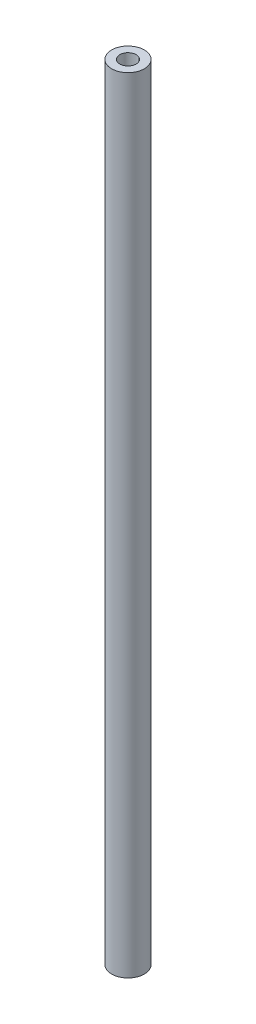
from build123d import *

# Parameters (mm, degrees)
SKETCH1_R           = 5
BOSS_EXTRUDE1_DEPTH = 240
SKETCH2_R           = 2.5
CUT_EXTRUDE1_DEPTH  = 30


with BuildPart() as part:
    # Sketch1 → Boss-Extrude1 (new body)
    with BuildSketch(Plane(origin=(0, 0, 0), x_dir=(1, 0, 0), z_dir=(0, 1, 0))):
        Circle(SKETCH1_R)
    extrude(amount=BOSS_EXTRUDE1_DEPTH)

    # Sketch2 → Cut-Extrude1 (cut)
    with BuildSketch(Plane(origin=(0, 240, 0), x_dir=(1, 0, 0), z_dir=(0, 1, 0))):
        Circle(SKETCH2_R)
    extrude(amount=-CUT_EXTRUDE1_DEPTH, mode=Mode.SUBTRACT)


solid = part.part
